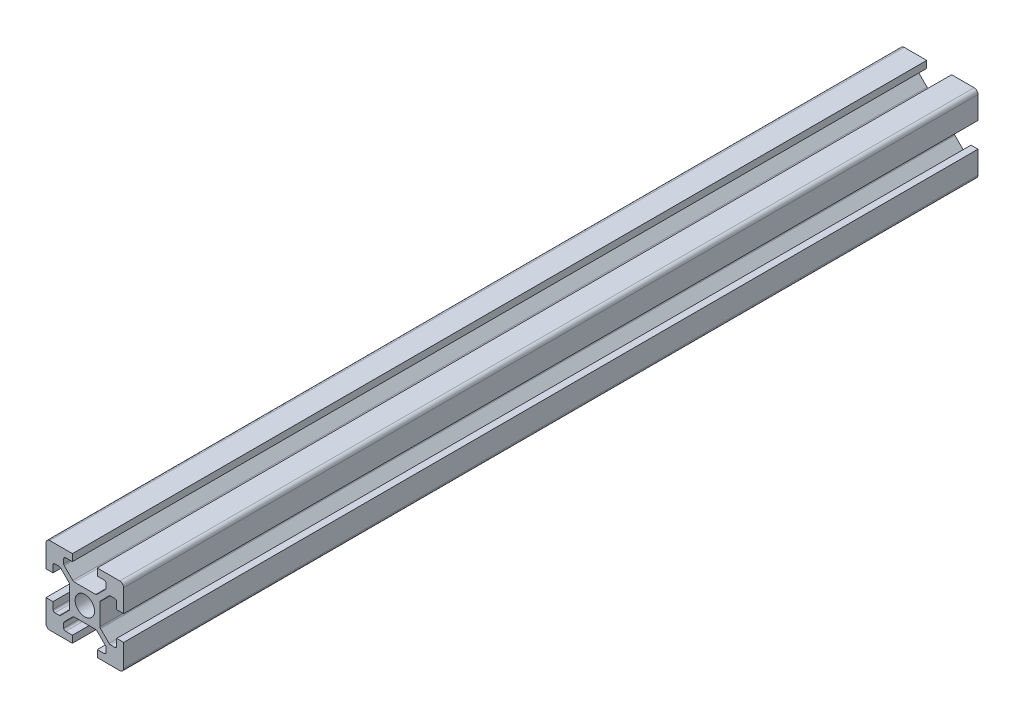
from build123d import *

# Parameters (mm, degrees)
SKETCH1_R           = 2.5
BOSS_EXTRUDE1_DEPTH = 220
FILLET1_R           = 1
FILLET2_R           = 0.5
FILLET3_R           = 0.5
FILLET4_R           = 0.5
FILLET5_R           = 0.5


with BuildPart() as part:
    # Sketch1 → Boss-Extrude1 (new body)
    with BuildSketch(Plane.XY):
        Polygon((13.2, 0), (13.2, 1.8), (15.45, 1.8), (15.45, 3.6), (12.95, 6.1), (7.05, 6.1), (4.55, 3.6), (4.55, 1.8), (6.8, 1.8), (6.8, 0), (0, 0), (0, 6.8), (1.8, 6.8), (1.8, 4.55), (3.6, 4.55), (6.1, 7.05), (6.1, 12.95), (3.6, 15.45), (1.8, 15.45), (1.8, 13.2), (0, 13.2), (0, 20), (6.8, 20), (6.8, 18.2), (4.55, 18.2), (4.55, 16.4), (7.05, 13.9), (12.95, 13.9), (15.45, 16.4), (15.45, 18.2), (13.2, 18.2), (13.2, 20), (20, 20), (20, 13.2), (18.2, 13.2), (18.2, 15.45), (16.4, 15.45), (13.9, 12.95), (13.9, 7.05), (16.4, 4.55), (18.2, 4.55), (18.2, 6.8), (20, 6.8), (20, 0), align=None)
        with Locations((10, 10)):
            Circle(SKETCH1_R, mode=Mode.SUBTRACT)
    extrude(amount=BOSS_EXTRUDE1_DEPTH)

    # Fillet1
    fillet1_edges = [part.edges().sort_by_distance(p)[0] for p in [
        (0, 0, 110),
        (0, 20, 110),
        (20, 20, 110),
        (20, 0, 110),
    ]]
    fillet(fillet1_edges, radius=FILLET1_R)

    # Fillet2
    fillet2_edges = [part.edges().sort_by_distance(p)[0] for p in [
        (4.55, 18.2, 110),
        (4.55, 16.4, 110),
        (7.05, 13.9, 110),
        (12.95, 13.9, 110),
        (15.45, 16.4, 110),
        (15.45, 18.2, 110),
    ]]
    fillet(fillet2_edges, radius=FILLET2_R)

    # Fillet3
    fillet3_edges = [part.edges().sort_by_distance(p)[0] for p in [
        (18.2, 15.45, 110),
        (16.4, 15.45, 110),
        (13.9, 12.95, 110),
        (13.9, 7.05, 110),
        (16.4, 4.55, 110),
        (18.2, 4.55, 110),
    ]]
    fillet(fillet3_edges, radius=FILLET3_R)

    # Fillet4
    fillet4_edges = [part.edges().sort_by_distance(p)[0] for p in [
        (1.8, 4.55, 110),
        (3.6, 4.55, 110),
        (6.1, 7.05, 110),
        (6.1, 12.95, 110),
        (3.6, 15.45, 110),
        (1.8, 15.45, 110),
    ]]
    fillet(fillet4_edges, radius=FILLET4_R)

    # Fillet5
    fillet5_edges = [part.edges().sort_by_distance(p)[0] for p in [
        (15.45, 1.8, 110),
        (15.45, 3.6, 110),
        (12.95, 6.1, 110),
        (7.05, 6.1, 110),
        (4.55, 3.6, 110),
        (4.55, 1.8, 110),
    ]]
    fillet(fillet5_edges, radius=FILLET5_R)


solid = part.part
